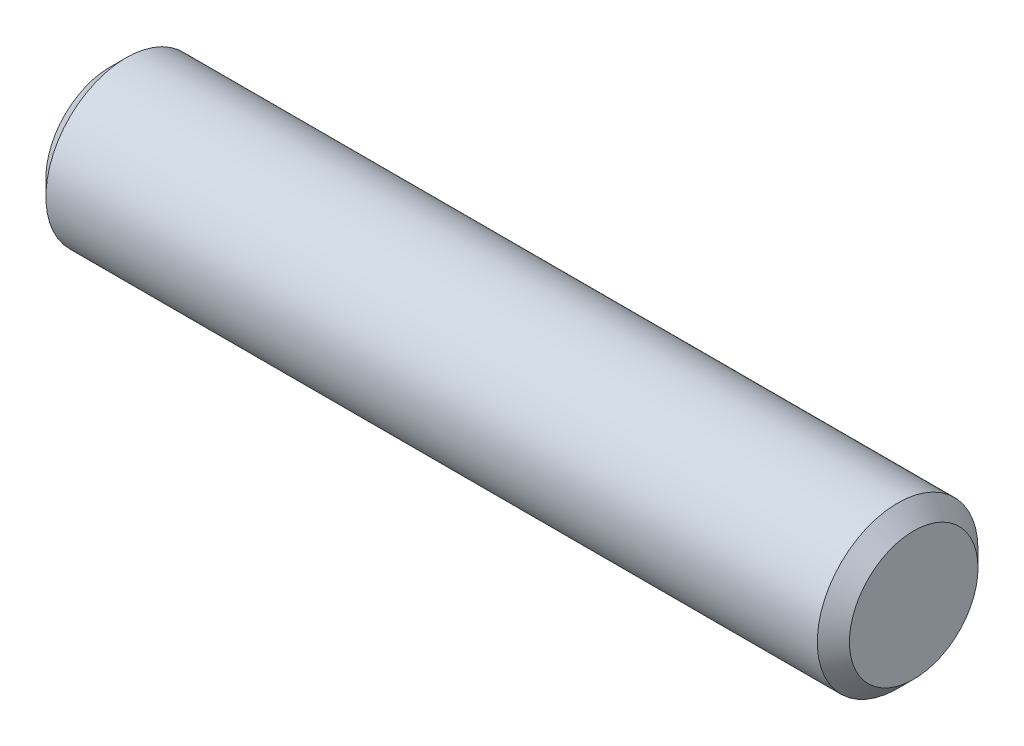
from build123d import *

# Parameters (mm, degrees)
SKETCH2_R           = 1.5875
EXTRUDE1_DEPTH      = 7.9375
EXTRUDE1_DEPTH_BACK = 7.9375
CHAMFER1_SIZE       = 0.3175


with BuildPart() as part:
    # Sketch2 → Extrude1 (new body, two sides)
    with BuildSketch(Plane(origin=(0, 0, 0), x_dir=(0, 0, -1), z_dir=(1, 0, 0))) as extrude1_sk:
        Circle(SKETCH2_R)
    extrude(amount=EXTRUDE1_DEPTH)
    extrude(extrude1_sk.sketch, amount=-EXTRUDE1_DEPTH_BACK)

    # Chamfer1
    chamfer1_edges = [part.edges().sort_by_distance(p)[0] for p in [
        (-7.9375, 0, 1.5875),
        (7.9375, 0, 1.5875),
    ]]
    chamfer(chamfer1_edges, length=CHAMFER1_SIZE)


solid = part.part
